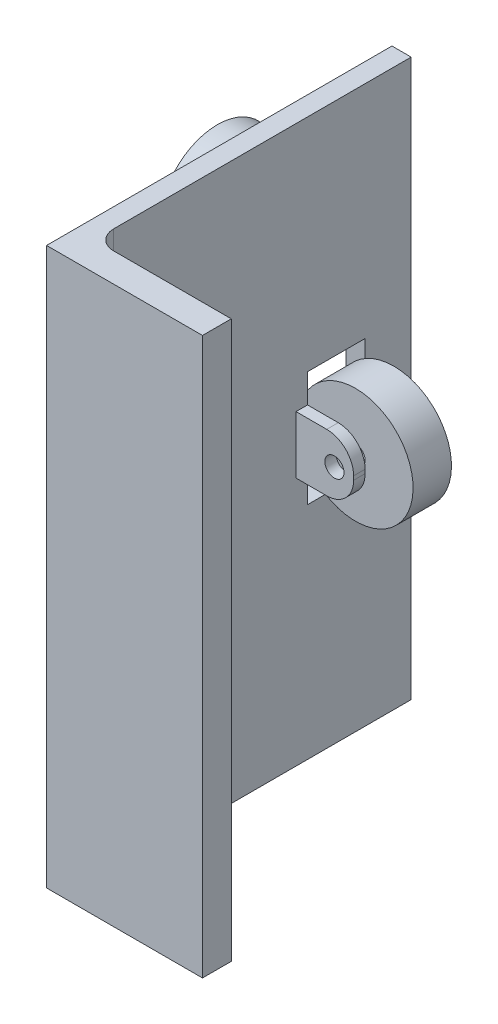
from build123d import *

# Parameters (mm, degrees)
BOSS_EXTRUDE1_DEPTH = 145
SKETCH3_R           = 15
BOSS_EXTRUDE2_DEPTH = 10
SKETCH4_W           = 15
SKETCH4_H           = 30
CUT_EXTRUDE1_DEPTH  = 10
SKETCH6_R           = 15
BOSS_EXTRUDE3_DEPTH = 10
SKETCH7_W           = 3
SKETCH7_H           = 15
BOSS_EXTRUDE4_DEPTH = 15
FILLET1_R           = 7
SKETCH8_R           = 2.5
CUT_EXTRUDE2_DEPTH  = 25


with BuildPart() as part:
    # Sketch1 → Boss-Extrude1 (new body)
    with BuildSketch(Plane(origin=(0, 0, 0), x_dir=(1, 0, 0), z_dir=(0, 1, 0))):
        with BuildLine():
            Line((0, 0), (0, 90))
            Line((0, 90), (5, 90))
            Line((5, 90), (5, 12.5))
            ThreePointArc((5, 12.5), (6.464466094, 8.964466094), (10, 7.5))
            Line((10, 7.5), (40.625, 7.5))
            Line((40.625, 7.5), (40.625, 0))
            Line((40.625, 0), (0, 0))
        make_face()
    extrude(amount=BOSS_EXTRUDE1_DEPTH)

    # Sketch3 → Boss-Extrude2 (add)
    with BuildSketch(Plane.ZY):
        with Locations((-54.5, 125)):
            Circle(SKETCH3_R)
        with Locations((-54.5, 20)):
            Circle(SKETCH3_R)
    extrude(amount=BOSS_EXTRUDE2_DEPTH)

    # Sketch4 → Cut-Extrude1 (cut)
    with BuildSketch(Plane.ZY):
        with Locations((-70.5, 72.5)):
            Rectangle(SKETCH4_W, SKETCH4_H)
    extrude(amount=-CUT_EXTRUDE1_DEPTH, mode=Mode.SUBTRACT)

    # Sketch7 → Boss-Extrude4 (add)
    with BuildSketch(Plane(origin=(5, 0, 0), x_dir=(0, 0, -1), z_dir=(1, 0, 0))):
        with Locations((79.5, 72.5)):
            Rectangle(SKETCH7_W, SKETCH7_H)
        with Locations((61.5, 72.5)):
            Rectangle(SKETCH7_W, SKETCH7_H)
    extrude(amount=BOSS_EXTRUDE4_DEPTH)

    # Fillet1
    fillet1_edges = [part.edges().sort_by_distance(p)[0] for p in [
        (20, 80, -61.5),
        (20, 65, -61.5),
        (20, 80, -79.5),
        (20, 65, -79.5),
    ]]
    fillet(fillet1_edges, radius=FILLET1_R)


with BuildPart() as body_2:
    # Sketch6 → Boss-Extrude3 (new body)
    with BuildSketch(Plane(origin=(0, 0, -65.5), x_dir=(-1, 0, 0), z_dir=(0, 0, -1))):
        with Locations((-15, 72.5)):
            Circle(SKETCH6_R)
    extrude(amount=BOSS_EXTRUDE3_DEPTH)


with BuildPart() as cut_extrude2_tool:
    # Sketch8 → Cut-Extrude2 (new body)
    with BuildSketch(Plane(origin=(0, 0, -81), x_dir=(-1, 0, 0), z_dir=(0, 0, -1))):
        with Locations((-15, 72.5)):
            Circle(SKETCH8_R)
    extrude(amount=-CUT_EXTRUDE2_DEPTH)


with BuildPart() as part_1:
    add(part.part)

    # Cut-Extrude2: cut by cut_extrude2_tool
    add(cut_extrude2_tool.part, mode=Mode.SUBTRACT)


with BuildPart() as body_2_1:
    add(body_2.part)

    # Cut-Extrude2: cut by cut_extrude2_tool
    add(cut_extrude2_tool.part, mode=Mode.SUBTRACT)


solid = Compound([part_1.part, body_2_1.part])
